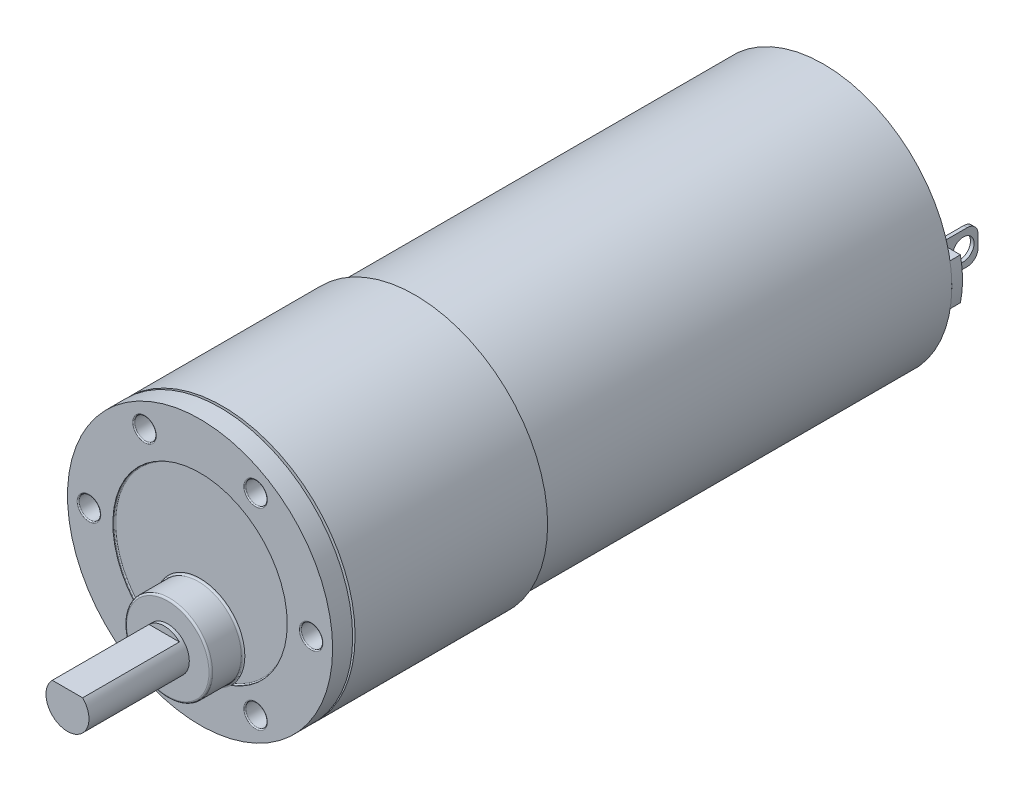
from build123d import *

# Parameters (mm, degrees)
ESQUISSE1_R             = 18.5
BOSS_EXTRU_1_DEPTH      = 30
ESQUISSE2_R             = 1.5
ENL_V_MAT_EXTRU_1_DEPTH = 8
ESQUISSE3_R             = 6
BOSS_EXTRU_2_DEPTH      = 4.5
ESQUISSE4_R             = 3
BOSS_EXTRU_3_DEPTH      = 14
CONG_1_R                = 0.25
ENL_V_START             = -13.5
ENL_V_MAT_EXTRU_2_DEPTH = 13.5
ESQUISSE6_R             = 12.1671446
ENL_V_MAT_EXTRU_3_DEPTH = 0.25
CONG_2_R                = 0.15
CONG_3_R                = 0.15
ESQUISSE7_R             = 17.9
BOSS_EXTRU_4_DEPTH      = 57
ESQUISSE8_R             = 6.45
BOSS_EXTRU_5_DEPTH      = 4.9
CONG_4_R                = 3
BOSS_EXTRU_6_DEPTH      = 1.5
ESQUISSE10_W            = 0.5
ESQUISSE10_H            = 4.721524129
BOSS_EXTRU_7_DEPTH      = 5.8
CONG_5_R                = 1.5
ESQUISSE11_R            = 1.5
ENL_V_MAT_EXTRU_4_DEPTH = 5.8
ENL_V_START_2           = -5.8
ESQUISSE12_R            = 1.5
ENL_V_MAT_EXTRU_5_DEPTH = 5.8
ESQUISSE13_W            = 0.337019912
ESQUISSE13_H            = 1.870001597


with BuildPart() as part:
    # Esquisse1 → Boss.-Extru.1 (new body)
    with BuildSketch(Plane.XY):
        with Locations((295.563452686, 228.453622661)):
            Circle(ESQUISSE1_R)
    extrude(amount=-BOSS_EXTRU_1_DEPTH)

    # Esquisse2 → Enlèv. mat.-Extru.1 (cut)
    with BuildSketch(Plane.XY):
        with Locations((280.063452686, 228.453622661)):
            Circle(ESQUISSE2_R)
        with Locations((287.813452686, 241.877016419)):
            Circle(ESQUISSE2_R)
        with Locations((303.313452686, 241.877016419)):
            Circle(ESQUISSE2_R)
        with Locations((311.063452686, 228.453622661)):
            Circle(ESQUISSE2_R)
        with Locations((303.313452686, 215.030228902)):
            Circle(ESQUISSE2_R)
        with Locations((287.813452686, 215.030228902)):
            Circle(ESQUISSE2_R)
    extrude(amount=-ENL_V_MAT_EXTRU_1_DEPTH, mode=Mode.SUBTRACT)

    # Esquisse3 → Boss.-Extru.2 (add)
    with BuildSketch(Plane.XY):
        with Locations((295.563452686, 221.453622661)):
            Circle(ESQUISSE3_R)
    extrude(amount=BOSS_EXTRU_2_DEPTH)

    # Esquisse4 → Boss.-Extru.3 (add)
    with BuildSketch(Plane.XY.offset(4.5)):
        with Locations((295.563452686, 221.453622661)):
            Circle(ESQUISSE4_R)
    extrude(amount=BOSS_EXTRU_3_DEPTH)

    # Congé1
    cong_1_edges = [part.edges().sort_by_distance(p)[0] for p in [
        (289.563452686, 221.453622661, 0),
        (289.563452686, 221.453622661, 4.5),
    ]]
    fillet(cong_1_edges, radius=CONG_1_R)

    # Esquisse5 → Enlèv. mat.-Extru.2 (cut)
    with BuildSketch(Plane.XY.offset(18.5).offset(ENL_V_START)):
        with BuildLine():
            Line((293.445774555, 223.578578973), (297.681130818, 223.578578973))
            ThreePointArc((297.681130818, 223.578578973), (295.563452686, 224.453622661), (293.445774555, 223.578578973))
        make_face()
    extrude(amount=ENL_V_MAT_EXTRU_2_DEPTH, mode=Mode.SUBTRACT)

    # Esquisse6 → Enlèv. mat.-Extru.3 (cut)
    with BuildSketch(Plane.XY):
        with Locations((295.563452686, 228.285283082)):
            Circle(ESQUISSE6_R)
    extrude(amount=-ENL_V_MAT_EXTRU_3_DEPTH, mode=Mode.SUBTRACT)

    # Congé2
    cong_2_edges = [part.edges().sort_by_distance(p)[0] for p in [
        (283.396308087, 228.285283082, -0.25),
    ]]
    fillet(cong_2_edges, radius=CONG_2_R)

    # Congé3
    cong_3_edges = [part.edges().sort_by_distance(p)[0] for p in [
        (278.563452686, 228.453622661, 0),
        (286.313452686, 215.030228902, 0),
        (301.813452686, 215.030228902, 0),
        (309.563452686, 228.453622661, 0),
        (286.313452686, 241.877016419, 0),
        (301.813452686, 241.877016419, 0),
    ]]
    fillet(cong_3_edges, radius=CONG_3_R)

    # Esquisse7 → Boss.-Extru.4 (add)
    with BuildSketch(Plane(origin=(0, 0, -30), x_dir=(-1, 0, 0), z_dir=(0, 0, -1))):
        with Locations((-295.563452686, 228.453622661)):
            Circle(ESQUISSE7_R)
    extrude(amount=BOSS_EXTRU_4_DEPTH)

    # Esquisse8 → Boss.-Extru.5 (add)
    with BuildSketch(Plane(origin=(0, 0, -87), x_dir=(-1, 0, 0), z_dir=(0, 0, -1))):
        with Locations((-295.563452686, 228.453622661)):
            Circle(ESQUISSE8_R)
    extrude(amount=BOSS_EXTRU_5_DEPTH)

    # Congé4
    cong_4_edges = [part.edges().sort_by_distance(p)[0] for p in [
        (302.013452686, 228.453622661, -91.9),
    ]]
    fillet(cong_4_edges, radius=CONG_4_R)

    # Esquisse9 → Boss.-Extru.6 (add)
    with BuildSketch(Plane(origin=(0, 0, -87), x_dir=(-1, 0, 0), z_dir=(0, 0, -1))):
        with BuildLine():
            Line((-282.698090425, 225.553622661), (-282.698090425, 231.353622661))
            Line((-282.698090425, 231.353622661), (-277.967314606, 231.353622661))
            ThreePointArc((-277.967314606, 231.353622661), (-277.663452686, 228.453622661), (-277.967314606, 225.553622661))
            Line((-277.967314606, 225.553622661), (-282.698090425, 225.553622661))
        make_face()
        with BuildLine():
            Line((-308.428814947, 225.553622661), (-308.428814947, 231.353622661))
            Line((-308.428814947, 231.353622661), (-313.159590766, 231.353622661))
            ThreePointArc((-313.159590766, 231.353622661), (-313.463452686, 228.453622661), (-313.159590766, 225.553622661))
            Line((-313.159590766, 225.553622661), (-308.428814947, 225.553622661))
        make_face()
    extrude(amount=BOSS_EXTRU_6_DEPTH)

    # Esquisse10 → Boss.-Extru.7 (add)
    with BuildSketch(Plane(origin=(0, 0, -88.5), x_dir=(-1, 0, 0), z_dir=(0, 0, -1))):
        with Locations((-309.565529022, 228.453622661)):
            Rectangle(ESQUISSE10_W, ESQUISSE10_H)
        with Locations((-281.56137635, 228.453622661)):
            Rectangle(ESQUISSE10_W, ESQUISSE10_H)
    extrude(amount=BOSS_EXTRU_7_DEPTH)

    # Congé5
    cong_5_edges = [part.edges().sort_by_distance(p)[0] for p in [
        (309.565529022, 230.814384725, -94.3),
        (281.56137635, 230.814384725, -94.3),
        (281.56137635, 226.092860596, -94.3),
        (309.565529022, 226.092860596, -94.3),
    ]]
    fillet(cong_5_edges, radius=CONG_5_R)

    # Esquisse11 → Enlèv. mat.-Extru.4 (cut)
    with BuildSketch(Plane(origin=(309.815529022, 0, 0), x_dir=(0, 0, -1), z_dir=(1, 0, 0))):
        with Locations((92.250189273, 228.453622661)):
            Circle(ESQUISSE11_R)
    extrude(amount=-ENL_V_MAT_EXTRU_4_DEPTH, mode=Mode.SUBTRACT)

    # Esquisse12 → Enlèv. mat.-Extru.5 (cut)
    with BuildSketch(Plane.ZY.offset(-281.31137635).offset(ENL_V_START_2)):
        with Locations((-92.250189273, 228.453622661)):
            Circle(ESQUISSE12_R)
    extrude(amount=ENL_V_MAT_EXTRU_5_DEPTH, mode=Mode.SUBTRACT)

    # Esquisse13 → Enlèvement de matière-Révolution2 (revolve, cut)
    with BuildSketch(Plane(origin=(295, 0, 0), x_dir=(0, 0, -1), z_dir=(1, 0, 0))):
        with Locations((2.964301217, 246.921340357)):
            Rectangle(ESQUISSE13_W, ESQUISSE13_H)
    revolve(axis=Axis((295, 228.33471706, -30), (0, 0, 1)), mode=Mode.SUBTRACT)


solid = part.part
